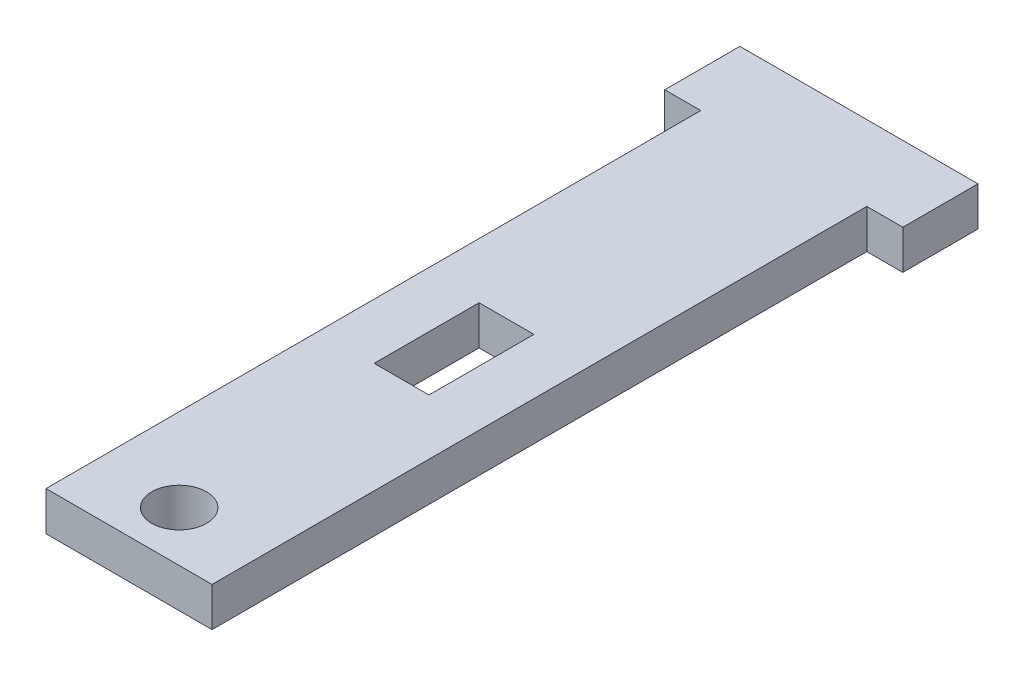
from build123d import *

# Parameters (mm, degrees)
BOSS_EXTRUDE1_DEPTH = 2.5
SKETCH2_R           = 1.75
SKETCH2_W           = 3.5
SKETCH2_H           = 6.7
CUT_EXTRUDE1_DEPTH  = 2.5


with BuildPart() as part:
    # Sketch1 → Boss-Extrude1 (new body)
    with BuildSketch(Plane(origin=(0, 0, 0), x_dir=(1, 0, 0), z_dir=(0, 1, 0))):
        Polygon((5.3, 0), (-5.3, 0), (-5.3, 41.8), (-7.6, 41.8), (-7.6, 46.6), (7.6, 46.6), (7.6, 41.8), (5.3, 41.8), align=None)
    extrude(amount=BOSS_EXTRUDE1_DEPTH)

    # Sketch2 → Cut-Extrude1 (cut)
    with BuildSketch(Plane(origin=(0, 0, 0), x_dir=(1, 0, 0), z_dir=(0, 1, 0))):
        with Locations((0, 3.2)):
            Circle(SKETCH2_R)
        with Locations((0, 20.75)):
            Rectangle(SKETCH2_W, SKETCH2_H)
    extrude(amount=CUT_EXTRUDE1_DEPTH, mode=Mode.SUBTRACT)


solid = part.part
